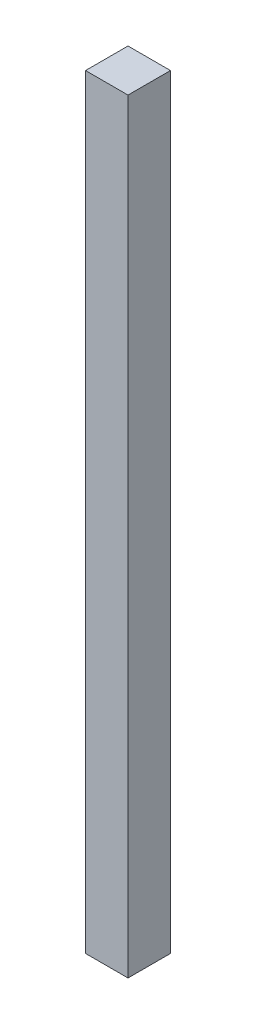
from build123d import *

# Parameters (mm, degrees)
SKETCH1_W           = 38.1
SKETCH1_H           = 38.1
BOSS_EXTRUDE1_DEPTH = 685.8


with BuildPart() as part:
    # Sketch1 → Boss-Extrude1 (new body)
    with BuildSketch(Plane(origin=(0, 0, 0), x_dir=(1, 0, 0), z_dir=(0, 1, 0))):
        with Locations((19.05, -19.05)):
            Rectangle(SKETCH1_W, SKETCH1_H)
    extrude(amount=BOSS_EXTRUDE1_DEPTH)


solid = part.part
